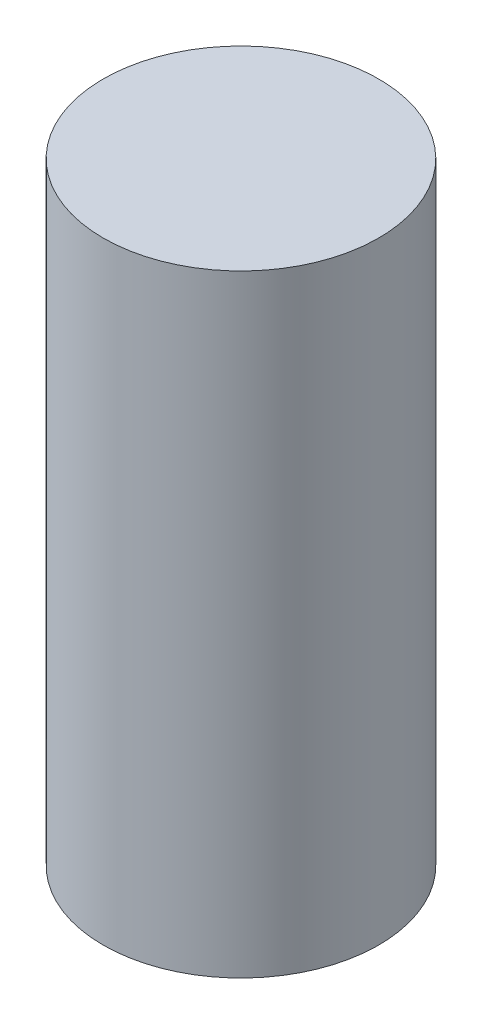
from build123d import *

# Parameters (mm, degrees)
SKETCH1_W = 2.25
SKETCH1_H = 10


with BuildPart() as part:
    # Sketch1 → Revolve1 (revolve)
    with BuildSketch(Plane(origin=(0, 0, 0), x_dir=(0, 0, -1), z_dir=(1, 0, 0))):
        with Locations((-1.125, -5)):
            Rectangle(SKETCH1_W, SKETCH1_H)
    revolve(axis=Axis((0, 4.444672131, 0), (0, -1, 0)))


solid = part.part
